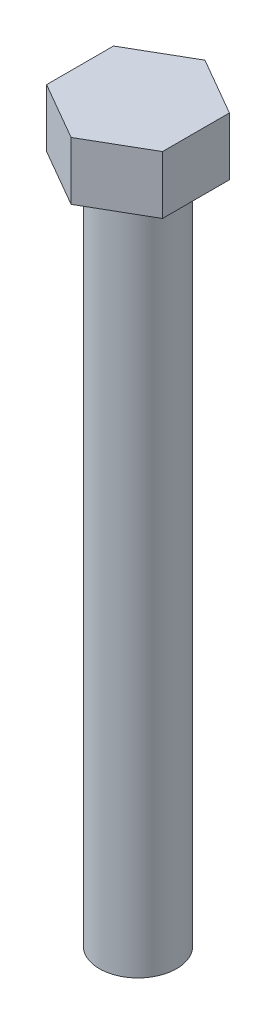
from build123d import *

# Parameters (mm, degrees)
EXTRUDE_1_DEPTH = 6
SKETCH_2_R      = 4
EXTRUDE_2_DEPTH = 70


with BuildPart() as part:
    # Эскиз1 → Бобышка-Вытянуть1 (new body)
    with BuildSketch(Plane(origin=(0, 0, 0), x_dir=(1, 0, 0), z_dir=(0, 1, 0))):
        Polygon((0, -6.92820323), (6, -3.464101615), (6, 3.464101615), (0, 6.92820323), (-6, 3.464101615), (-6, -3.464101615), align=None)
    extrude(amount=EXTRUDE_1_DEPTH)

    # Эскиз2 → Бобышка-Вытянуть2 (add)
    with BuildSketch(Plane.XZ):
        Circle(SKETCH_2_R)
    extrude(amount=EXTRUDE_2_DEPTH)


solid = part.part
